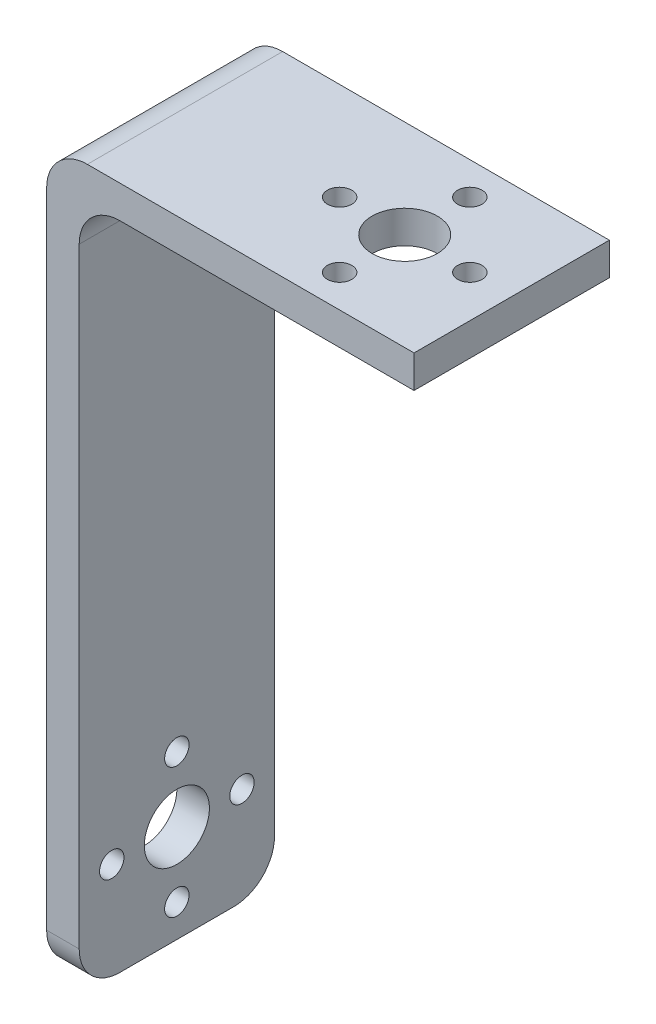
from build123d import *

# Parameters (mm, degrees)
BOSS_EXTRUDE1_DEPTH = 24
SKETCH3_R           = 4
SKETCH3_R_2         = 1.5
CUT_EXTRUDE2_DEPTH  = 4
SKETCH6_R           = 4
SKETCH6_R_2         = 1.5
CUT_EXTRUDE3_DEPTH  = 4
FILLET1_R           = 5


with BuildPart() as part:
    # Sketch1 → Boss-Extrude1 (new body)
    with BuildSketch(Plane.XY):
        Polygon((-35.947712149, -38.738038278), (-35.947712149, 46.261961722), (5.197050303, 46.261961722), (5.197050303, 50.261961722), (-39.947712149, 50.261961722), (-39.947712149, -38.738038278), align=None)
    extrude(amount=BOSS_EXTRUDE1_DEPTH)

    # Sketch3 → Cut-Extrude2 (cut)
    with BuildSketch(Plane.ZY.offset(39.947712149)):
        with Locations((12, -26.738038278)):
            Circle(SKETCH3_R)
        with Locations((20, -26.738038278)):
            Circle(SKETCH3_R_2)
        with Locations((12, -34.738038278)):
            Circle(SKETCH3_R_2)
        with Locations((4, -26.738038278)):
            Circle(SKETCH3_R_2)
        with Locations((12, -18.738038278)):
            Circle(SKETCH3_R_2)
    extrude(amount=-CUT_EXTRUDE2_DEPTH, mode=Mode.SUBTRACT)

    # Sketch6 → Cut-Extrude3 (cut)
    with BuildSketch(Plane(origin=(0, 50.261961722, 0), x_dir=(1, 0, 0), z_dir=(0, 1, 0))):
        with Locations((-7.947712149, -12)):
            Circle(SKETCH6_R)
        with Locations((0.052287851, -12)):
            Circle(SKETCH6_R_2)
        with Locations((-7.947712149, -20)):
            Circle(SKETCH6_R_2)
        with Locations((-15.947712149, -12)):
            Circle(SKETCH6_R_2)
        with Locations((-7.947712149, -4)):
            Circle(SKETCH6_R_2)
    extrude(amount=-CUT_EXTRUDE3_DEPTH, mode=Mode.SUBTRACT)

    # Fillet1
    fillet1_edges = [part.edges().sort_by_distance(p)[0] for p in [
        (-35.947712149, 46.261961722, 12),
        (-39.947712149, 50.261961722, 12),
        (-37.947712149, -38.738038278, 24),
        (-37.947712149, -38.738038278, 0),
    ]]
    fillet(fillet1_edges, radius=FILLET1_R)


solid = part.part
